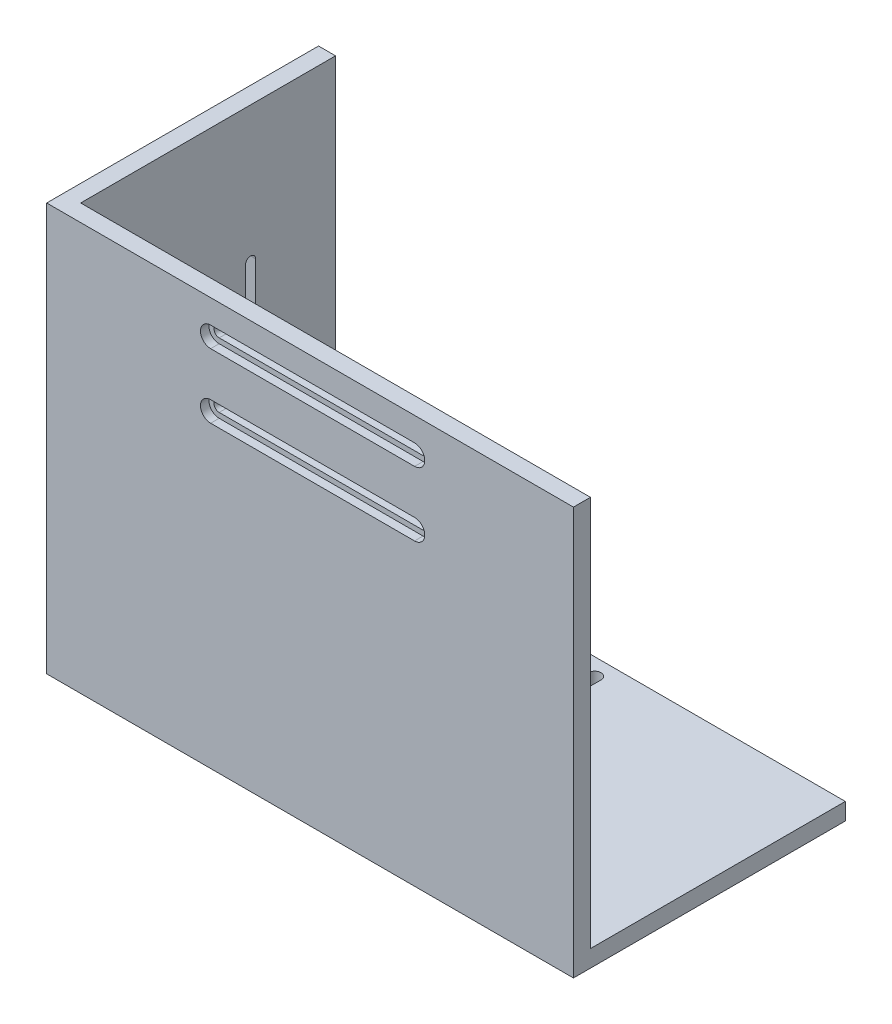
from build123d import *

# Parameters (mm, degrees)
SKETCH_1_W          = 5
SKETCH_1_H          = 120
EXTRUDE_1_DEPTH     = 80
SKETCH_2_W          = 80
SKETCH_2_H          = 5
EXTRUDE_2_DEPTH     = 150
CUT_EXTRUDE_1_REACH = 7
SKETCH_4_W          = 5
SKETCH_4_H          = 115
EXTRUDE_3_DEPTH     = 150
CUT_EXTRUDE_4_DEPTH = 2.5
CUT_EXTRUDE_5_DEPTH = 6
CUT_EXTRUDE_6_DEPTH = 6


with BuildPart() as part:
    # 草图1 → 凸台-拉伸1 (new body)
    with BuildSketch(Plane.XY):
        with Locations((2.5, -60)):
            Rectangle(SKETCH_1_W, SKETCH_1_H)
    extrude(amount=EXTRUDE_1_DEPTH)

    # 草图2 → 凸台-拉伸2 (add)
    with BuildSketch(Plane(origin=(5, 0, 0), x_dir=(0, 0, -1), z_dir=(1, 0, 0))):
        with Locations((-40, -117.5)):
            Rectangle(SKETCH_2_W, SKETCH_2_H)
    extrude(amount=EXTRUDE_2_DEPTH)

    # 草图3 → 切除-拉伸1 (cut, up to next)
    with BuildSketch(Plane(origin=(5, 0, 0), x_dir=(0, 0, -1), z_dir=(1, 0, 0)), mode=Mode.PRIVATE) as cut_extrude_1_sk1:
        with BuildLine():
            Line((-53.5, -40), (-53.5, -80))
            ThreePointArc((-53.5, -80), (-55, -81.5), (-56.5, -80))
            Line((-56.5, -80), (-56.5, -40))
            ThreePointArc((-56.5, -40), (-55, -38.5), (-53.5, -40))
        make_face()
    cut_extrude_1_tool1 = extrude(cut_extrude_1_sk1.sketch, amount=-CUT_EXTRUDE_1_REACH, mode=Mode.PRIVATE) & part.part
    add(cut_extrude_1_tool1.solids().sort_by_distance((5, -60, 55))[0], mode=Mode.SUBTRACT)
    # 草图3 → 切除-拉伸1 (cut, up to next)
    with BuildSketch(Plane(origin=(5, 0, 0), x_dir=(0, 0, -1), z_dir=(1, 0, 0)), mode=Mode.PRIVATE) as cut_extrude_1_sk2:
        with BuildLine():
            Line((-26.5, -40), (-26.5, -80))
            ThreePointArc((-26.5, -80), (-25, -81.5), (-23.5, -80))
            Line((-23.5, -80), (-23.5, -40))
            ThreePointArc((-23.5, -40), (-25, -38.5), (-26.5, -40))
        make_face()
    cut_extrude_1_tool2 = extrude(cut_extrude_1_sk2.sketch, amount=-CUT_EXTRUDE_1_REACH, mode=Mode.PRIVATE) & part.part
    add(cut_extrude_1_tool2.solids().sort_by_distance((5, -60, 25))[0], mode=Mode.SUBTRACT)
    # 草图3 → 切除-拉伸1 (cut, up to next)
    with BuildSketch(Plane(origin=(5, 0, 0), x_dir=(0, 0, -1), z_dir=(1, 0, 0)), mode=Mode.PRIVATE) as cut_extrude_1_sk3:
        with BuildLine():
            Line((-62.5, -95), (-17.5, -95))
            ThreePointArc((-17.5, -95), (-12.5, -100), (-17.5, -105))
            Line((-17.5, -105), (-62.5, -105))
            ThreePointArc((-62.5, -105), (-67.5, -100), (-62.5, -95))
        make_face()
    cut_extrude_1_tool3 = extrude(cut_extrude_1_sk3.sketch, amount=-CUT_EXTRUDE_1_REACH, mode=Mode.PRIVATE) & part.part
    add(cut_extrude_1_tool3.solids().sort_by_distance((5, -100, 40))[0], mode=Mode.SUBTRACT)

    # 草图4 → 凸台-拉伸3 (add)
    with BuildSketch(Plane(origin=(5, 0, 0), x_dir=(0, 0, -1), z_dir=(1, 0, 0))):
        with Locations((-77.5, -57.5)):
            Rectangle(SKETCH_4_W, SKETCH_4_H)
    extrude(amount=EXTRUDE_3_DEPTH)

    # 草图8 → 切除-拉伸4 (cut)
    with BuildSketch(Plane.XY.offset(80)):
        with BuildLine():
            Line((48.25, -7), (108.25, -7))
            ThreePointArc((108.25, -7), (111.25, -10), (108.25, -13))
            Line((108.25, -13), (48.25, -13))
            ThreePointArc((48.25, -13), (45.25, -10), (48.25, -7))
        make_face()
        with BuildLine():
            Line((48.25, -32), (108.25, -32))
            ThreePointArc((108.25, -32), (111.25, -29), (108.25, -26))
            Line((108.25, -26), (48.25, -26))
            ThreePointArc((48.25, -26), (45.25, -29), (48.25, -32))
        make_face()
    extrude(amount=-CUT_EXTRUDE_4_DEPTH, mode=Mode.SUBTRACT)

    # 草图6 → 切除-拉伸5 (cut, through all)
    with BuildSketch(Plane(origin=(0, 0, 75), x_dir=(-1, 0, 0), z_dir=(0, 0, -1))):
        with BuildLine():
            Line((-48.25, -11.5), (-108.25, -11.5))
            ThreePointArc((-108.25, -11.5), (-109.75, -10), (-108.25, -8.5))
            Line((-108.25, -8.5), (-48.25, -8.5))
            ThreePointArc((-48.25, -8.5), (-46.75, -10), (-48.25, -11.5))
        make_face()
        with BuildLine():
            Line((-48.25, -27.5), (-108.25, -27.5))
            ThreePointArc((-108.25, -27.5), (-109.75, -29), (-108.25, -30.5))
            Line((-108.25, -30.5), (-48.25, -30.5))
            ThreePointArc((-48.25, -30.5), (-46.75, -29), (-48.25, -27.5))
        make_face()
    extrude(amount=-CUT_EXTRUDE_5_DEPTH, mode=Mode.SUBTRACT)

    # 草图9 → 切除-拉伸6 (cut, through all)
    with BuildSketch(Plane(origin=(0, -115, 0), x_dir=(1, 0, 0), z_dir=(0, 1, 0))):
        with BuildLine():
            Line((80.25, -10), (80.25, -59))
            ThreePointArc((80.25, -59), (76.25, -63), (72.25, -59))
            Line((72.25, -59), (72.25, -10))
            ThreePointArc((72.25, -10), (76.25, -6), (80.25, -10))
        make_face()
        with BuildLine():
            Line((67.75, -5), (67.75, -65))
            ThreePointArc((67.75, -65), (66.25, -66.5), (64.75, -65))
            Line((64.75, -65), (64.75, -5))
            ThreePointArc((64.75, -5), (66.25, -3.5), (67.75, -5))
        make_face()
        with BuildLine():
            Line((88.109913979, -5), (88.109913979, -65))
            ThreePointArc((88.109913979, -65), (86.25, -66.859913979), (84.390086021, -65))
            Line((84.390086021, -65), (84.390086021, -5))
            ThreePointArc((84.390086021, -5), (86.25, -3.140086021), (88.109913979, -5))
        make_face()
    extrude(amount=-CUT_EXTRUDE_6_DEPTH, mode=Mode.SUBTRACT)


solid = part.part
